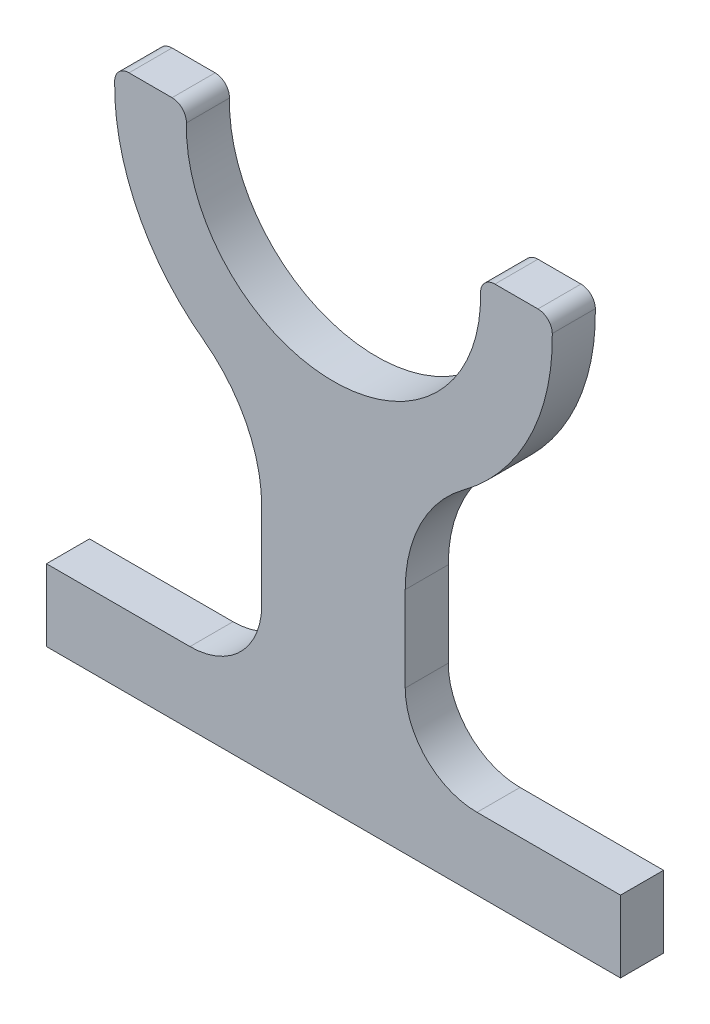
from build123d import *

# Parameters (mm, degrees)
BOSS_EXTRU_1_DEPTH = 3


with BuildPart() as part:
    # Esquisse1 → Boss.-Extru.1 (new body, symmetric)
    with BuildSketch(Plane.XY):
        with BuildLine():
            Line((-40, 0), (40, 0))
            Line((40, 0), (40, 10))
            Line((40, 10), (20, 10))
            ThreePointArc((20, 10), (12.928932188, 12.928932188), (10, 20))
            Line((10, 20), (10, 31.876730806))
            ThreePointArc((10, 31.876730806), (12.144695993, 40.88717579), (18.118811881, 47.965154249))
            ThreePointArc((18.118811881, 47.965154249), (27.348830005, 58.998463148), (30.495305887, 73.035087719))
            ThreePointArc((30.495305887, 73.035087719), (29.897366986, 74.426565007), (28.495613698, 75))
            Line((28.495613698, 75), (22.494443758, 75))
            ThreePointArc((22.494443758, 75), (21.064603052, 74.398411798), (20.494937647, 72.955555556))
            ThreePointArc((20.494937647, 72.955555556), (0, 52), (-20.494937647, 72.955555556))
            ThreePointArc((-20.494937647, 72.955555556), (-21.064603052, 74.398411798), (-22.494443758, 75))
            Line((-22.494443758, 75), (-28.495613698, 75))
            ThreePointArc((-28.495613698, 75), (-29.897366986, 74.426565007), (-30.495305887, 73.035087719))
            ThreePointArc((-30.495305887, 73.035087719), (-27.348830005, 58.998463148), (-18.118811881, 47.965154249))
            ThreePointArc((-18.118811881, 47.965154249), (-12.144695993, 40.88717579), (-10, 31.876730806))
            Line((-10, 31.876730806), (-10, 20))
            ThreePointArc((-10, 20), (-12.928932188, 12.928932188), (-20, 10))
            Line((-20, 10), (-40, 10))
            Line((-40, 10), (-40, 0))
        make_face()
    extrude(amount=BOSS_EXTRU_1_DEPTH, both=True)


solid = part.part
